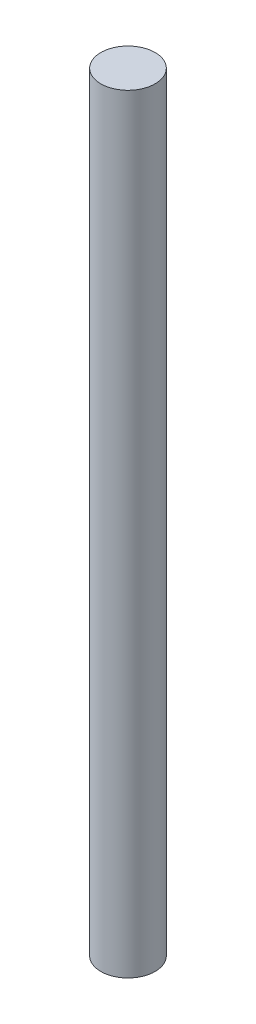
from build123d import *

# Parameters (mm, degrees)
SKETCH1_R           = 1.5
BOSS_EXTRUDE1_DEPTH = 42.5


with BuildPart() as part:
    # Sketch1 → Boss-Extrude1 (new body)
    with BuildSketch(Plane(origin=(0, 0, 0), x_dir=(1, 0, 0), z_dir=(0, 1, 0))):
        with Locations(Location((0, 0, 0), (0, 0, 270))):  # turned: the seam where the file's is
            Circle(SKETCH1_R)
    extrude(amount=BOSS_EXTRUDE1_DEPTH)


solid = part.part
